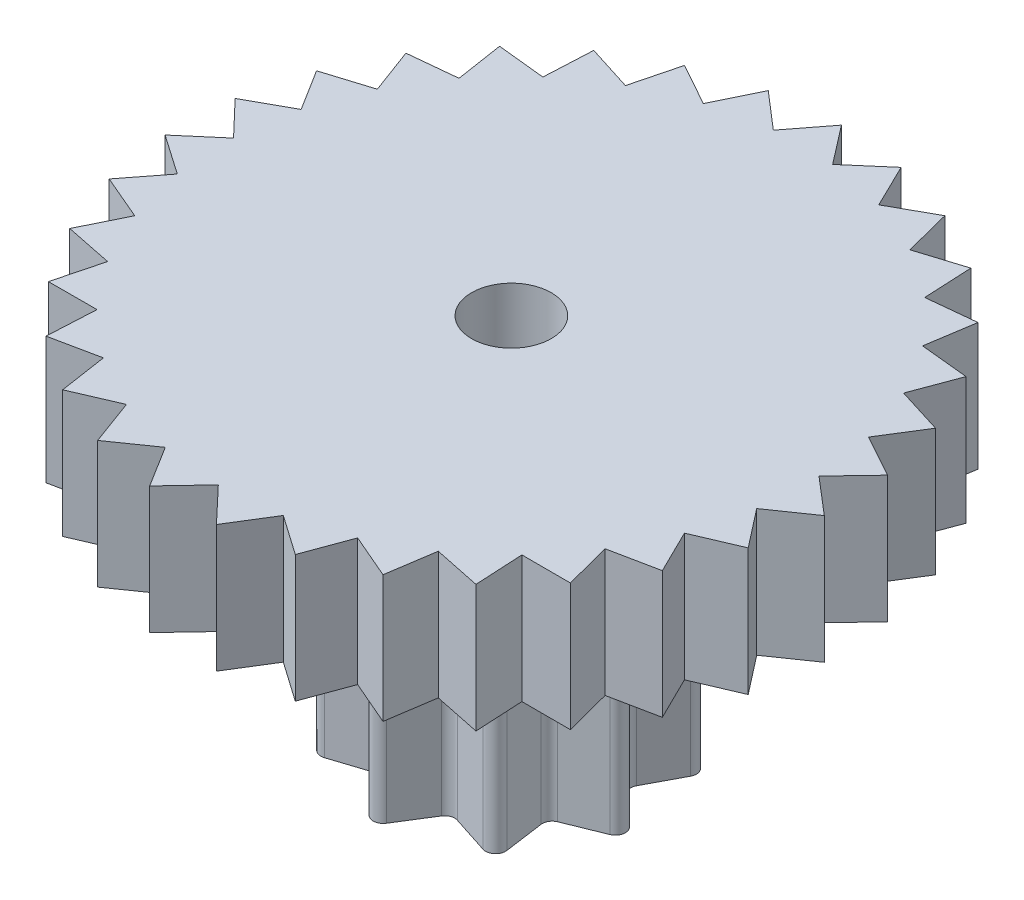
from build123d import *

# Parameters (mm, degrees)
SKETCH2_R          = 0.8
CUT_EXTRUDE1_DEPTH = 8.4
CUT_EXTRUDE2_DEPTH = 8.4
CIRPATTERN1_COUNT  = 31
CUT_EXTRUDE3_DEPTH = 4.85
CIRPATTERN2_COUNT  = 9
FILLET1_R          = 0.2


with BuildPart() as part:
    # Sketch1 → Revolve1 (revolve)
    with BuildSketch(Plane.XY):
        Polygon((-6.625, 7.4), (-6.625, 4.85), (-2.95, 4.85), (-2.95, 0), (0, 0), (0, 7.4), align=None)
    revolve(axis=Axis((0, 7.4, 0), (0, -1, 0)))

    # Sketch2 → Cut-Extrude1 (cut, through all)
    with BuildSketch(Plane(origin=(0, 7.4, 0), x_dir=(1, 0, 0), z_dir=(0, 1, 0))):
        Circle(SKETCH2_R)
    extrude(amount=-CUT_EXTRUDE1_DEPTH, mode=Mode.SUBTRACT)

    # Sketch4 → Cut-Extrude2 (cut, through all)
    with BuildSketch(Plane(origin=(0, 7.4, 0), x_dir=(1, 0, 0), z_dir=(0, 1, 0))):
        with BuildLine():
            Line((1.333602696, 6.489385861), (0.595196913, 5.853049041))
            Line((0.595196913, 5.853049041), (0, 6.625))
            ThreePointArc((0, 6.625), (0.670240133, 6.591009267), (1.333602696, 6.489385861))
        make_face()
    cut_extrude2 = extrude(amount=-CUT_EXTRUDE2_DEPTH, mode=Mode.SUBTRACT)

    # CirPattern1: Cut-Extrude2 ×31 about axis
    cirpattern1_axis = Axis((0, 0, 0), (0, 1, 0))
    for i in range(1, CIRPATTERN1_COUNT):
        add(cut_extrude2.rotate(cirpattern1_axis, i * 360 / CIRPATTERN1_COUNT), mode=Mode.SUBTRACT)

    # Sketch5 → Cut-Extrude3 (cut)
    with BuildSketch(Plane.XZ):
        with BuildLine():
            Line((0, 2.95), (0.67909598, 1.865800872))
            Line((0.67909598, 1.865800872), (1.896223449, 2.259831107))
            ThreePointArc((1.896223449, 2.259831107), (1.008959423, 2.772093231), (0, 2.95))
        make_face()
    cut_extrude3 = extrude(amount=-CUT_EXTRUDE3_DEPTH, mode=Mode.SUBTRACT)

    # CirPattern2: Cut-Extrude3 ×9 about axis
    cirpattern2_axis = Axis((0, 0, 0), (0, 1, 0))
    for i in range(1, CIRPATTERN2_COUNT):
        add(cut_extrude3.rotate(cirpattern2_axis, i * 360 / CIRPATTERN2_COUNT), mode=Mode.SUBTRACT)

    # Fillet1
    fillet1_edges = [part.edges().sort_by_distance(p)[0] for p in [
        (0, 2.425, 2.95),
        (1.896223449, 2.425, 2.259831107),
        (0.67909598, 2.425, 1.865800872),
        (2.905182871, 2.425, 0.512262124),
        (1.719531385, 2.425, 0.992771908),
        (2.554774941, 2.425, -1.475),
        (1.955378943, 2.425, -0.344786065),
        (1.008959423, 2.425, -2.772093231),
        (-1.008959423, 2.425, -2.772093231),
        (0, 2.425, -1.985543815),
        (-2.554774941, 2.425, -1.475),
        (-1.276282963, 2.425, -1.521014806),
        (-2.905182871, 2.425, 0.512262124),
        (-1.955378943, 2.425, -0.344786065),
        (-1.896223449, 2.425, 2.259831107),
        (-1.719531385, 2.425, 0.992771908),
        (-0.67909598, 2.425, 1.865800872),
    ]]
    fillet(fillet1_edges, radius=FILLET1_R)


solid = part.part
